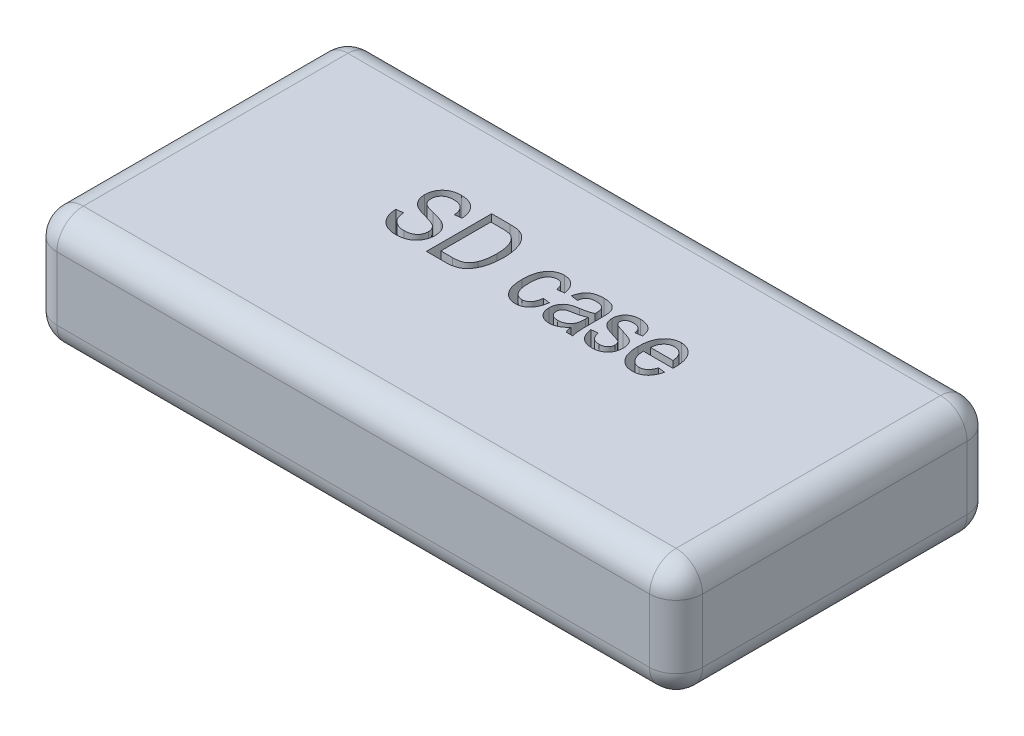
from build123d import *

# Parameters (mm, degrees)
SKETCH1_W           = 122
SKETCH1_H           = 60
BOSS_EXTRUDE1_DEPTH = 22
FILLET1_R           = 5
CUT_EXTRUDE1_DEPTH  = 23


with BuildPart() as part:
    # Sketch1 → Boss-Extrude1 (new body)
    with BuildSketch(Plane(origin=(0, 0, 0), x_dir=(1, 0, 0), z_dir=(0, 1, 0))):
        with Locations((56.214276145, -30)):
            Rectangle(SKETCH1_W, SKETCH1_H)
    extrude(amount=BOSS_EXTRUDE1_DEPTH)

    # Fillet1
    fillet1_edges = [part.edges().sort_by_distance(p)[0] for p in [
        (117.214276145, 22, 30),
        (56.214276145, 22, 0),
        (-4.785723855, 22, 30),
        (56.214276145, 0, 0),
        (117.214276145, 0, 30),
        (56.214276145, 0, 60),
        (-4.785723855, 0, 30),
        (-4.785723855, 11, 0),
        (117.214276145, 11, 0),
        (117.214276145, 11, 60),
        (-4.785723855, 11, 60),
        (56.214276145, 22, 60),
    ]]
    fillet(fillet1_edges, radius=FILLET1_R)

    # Sketch2 → Cut-Extrude1 (cut, through all)
    with BuildSketch(Plane(origin=(0, 22, 0), x_dir=(1, 0, 0), z_dir=(0, 1, 0))):
        with BuildLine():
            Line((30.277592906, -25.997425426), (31.55841677, -25.837322443))
            add(Edge.make_bspline(
                [(31.55841677, -25.837322443), (31.577066313, -26.00038168), (31.612435314, -26.309624773), (31.709305075, -26.742693066), (31.838868686, -27.118940399), (31.998936064, -27.445946572), (32.204060604, -27.72313712), (32.438365704, -27.972423696), (32.714343491, -28.189904924), (33.023274321, -28.379767363), (33.363302519, -28.533001799), (33.728113356, -28.638882457), (34.112557122, -28.706649404), (34.37577034, -28.714938862), (34.510315518, -28.719176136)],
                knots=[0, 0, 0, 0, 0.000492131, 0.00093333, 0.001328117, 0.001683882, 0.002020644, 0.00235862, 0.002707503, 0.00307133, 0.003444204, 0.003822551, 0.004208318, 0.004611706, 0.004611706, 0.004611706, 0.004611706], degree=3))
            add(Edge.make_bspline(
                [(34.510315518, -28.719176136), (34.606289806, -28.717225769), (34.792808014, -28.713435389), (35.064400108, -28.684926325), (35.320211863, -28.641980766), (35.557837712, -28.575170014), (35.781695147, -28.497041794), (35.985482284, -28.392881699), (36.176183321, -28.27516573), (36.348259767, -28.138113086), (36.499993433, -27.984070402), (36.637529507, -27.822402954), (36.749356762, -27.645416872), (36.84365281, -27.460090561), (36.912803688, -27.261861617), (36.966439022, -27.054677289), (36.996340563, -26.83466605), (37.00002984, -26.684619237), (37.00191819, -26.607818049)],
                knots=[0, 0, 0, 0, 0.000287859, 0.000559431, 0.000818537, 0.00106493, 0.001299175, 0.001528519, 0.001749936, 0.001970674, 0.00218648, 0.002397878, 0.002606053, 0.002813022, 0.003020339, 0.003234515, 0.003454216, 0.003684581, 0.003684581, 0.003684581, 0.003684581], degree=3))
            add(Edge.make_bspline(
                [(37.00191819, -26.607818049), (36.999164726, -26.519239483), (36.993801647, -26.346709956), (36.948152981, -26.095552712), (36.870319766, -25.862803318), (36.764360847, -25.646680063), (36.627512524, -25.448918545), (36.458509171, -25.270486461), (36.257688922, -25.112761562), (36.066067833, -24.993145513), (35.880958717, -24.906022024), (35.70607142, -24.830922657), (35.495451499, -24.751705286), (35.249440208, -24.666442309), (34.967959652, -24.577616667), (34.650854714, -24.482442924), (34.29923378, -24.379673344), (34.051792745, -24.311800444), (33.922437378, -24.276318359)],
                knots=[0, 0, 0, 0, 0.000265595, 0.000517315, 0.000762549, 0.000999727, 0.001237051, 0.001481262, 0.001734036, 0.002001334, 0.002156857, 0.002347374, 0.00257224, 0.002831733, 0.003128414, 0.003457639, 0.003824976, 0.00422737, 0.00422737, 0.00422737, 0.00422737], degree=3))
            add(Edge.make_bspline(
                [(33.922437378, -24.276318359), (33.806349655, -24.243564189), (33.582630724, -24.180441854), (33.261811788, -24.079421558), (32.966292112, -23.981362918), (32.697893266, -23.876745172), (32.453244467, -23.777388822), (32.237161985, -23.67076456), (32.046336696, -23.5663619), (31.826878867, -23.427858855), (31.587177658, -23.234149302), (31.3331276, -22.975307862), (31.11119846, -22.688692982), (30.92603839, -22.374329704), (30.77586493, -22.036078005), (30.676424658, -21.671467135), (30.60706887, -21.287860104), (30.600927725, -21.023717618), (30.597798872, -20.889139626)],
                knots=[0, 0, 0, 0, 0.000361835, 0.000697312, 0.001009001, 0.001295651, 0.001561399, 0.001800823, 0.002018045, 0.002213747, 0.002578648, 0.002939522, 0.003299788, 0.003663177, 0.004031738, 0.004406286, 0.004794519, 0.005197775, 0.005197775, 0.005197775, 0.005197775], degree=3))
            add(Edge.make_bspline(
                [(30.597798872, -20.889139626), (30.600559784, -20.76807724), (30.605987179, -20.530092984), (30.652319741, -20.181772345), (30.725760178, -19.849196535), (30.835347885, -19.535917672), (30.969423442, -19.237474036), (31.139216896, -18.95985585), (31.335554914, -18.696410222), (31.562869089, -18.453398878), (31.81323729, -18.230532002), (32.089523637, -18.03897683), (32.385895856, -17.876652768), (32.702415899, -17.739503585), (33.041993734, -17.638089679), (33.401401426, -17.566704951), (33.781118878, -17.519795733), (34.041536328, -17.514621238), (34.175099898, -17.51196733)],
                knots=[0, 0, 0, 0, 0.000363044, 0.000713671, 0.001052304, 0.00138299, 0.001707621, 0.002031963, 0.002357173, 0.002691725, 0.003028486, 0.003360899, 0.003697912, 0.004040842, 0.004393791, 0.004758803, 0.00513922, 0.005539759, 0.005539759, 0.005539759, 0.005539759], degree=3))
            add(Edge.make_bspline(
                [(34.175099898, -17.51196733), (34.35719142, -17.517050895), (34.712499826, -17.526970268), (35.227898377, -17.609929954), (35.707868725, -17.750473921), (36.150586229, -17.946043321), (36.552594363, -18.192936225), (36.906997964, -18.492649911), (37.21618248, -18.838481325), (37.473394422, -19.234151478), (37.68157221, -19.670613927), (37.834011705, -20.145937276), (37.933392967, -20.657569369), (37.952641474, -21.012094016), (37.962536088, -21.194335938)],
                knots=[0, 0, 0, 0, 0.000546045, 0.001065476, 0.001560997, 0.002042581, 0.002513263, 0.002971297, 0.003430211, 0.003899941, 0.004382206, 0.004876646, 0.00539376, 0.005940766, 0.005940766, 0.005940766, 0.005940766], degree=3))
            Line((37.962536088, -21.194335938), (36.681712225, -21.35443892))
            add(Edge.make_bspline(
                [(36.681712225, -21.35443892), (36.672316383, -21.255855325), (36.653993766, -21.063609704), (36.603368121, -20.78705463), (36.538662161, -20.529202847), (36.457537424, -20.29146418), (36.355599232, -20.074719086), (36.242103692, -19.876502208), (36.109906318, -19.698861729), (35.962414348, -19.540822493), (35.798008814, -19.402425539), (35.618890367, -19.281124751), (35.423536101, -19.178379604), (35.211598672, -19.096488274), (34.98583641, -19.030596046), (34.743501841, -18.986773115), (34.485955522, -18.958775941), (34.308595597, -18.954888205), (34.217627253, -18.952894176)],
                knots=[0, 0, 0, 0, 0.000296976, 0.000579126, 0.000842449, 0.001094032, 0.001331303, 0.001559991, 0.001778134, 0.001994056, 0.002207061, 0.002421456, 0.002641896, 0.002867665, 0.003102017, 0.003346356, 0.003605487, 0.003878346, 0.003878346, 0.003878346, 0.003878346], degree=3))
            add(Edge.make_bspline(
                [(34.217627253, -18.952894176), (34.12496947, -18.953687804), (33.945874581, -18.955221778), (33.685393724, -18.985480822), (33.441478957, -19.025443152), (33.213799227, -19.086298044), (33.004316567, -19.163098421), (32.810116594, -19.256871096), (32.633836752, -19.368477689), (32.474522462, -19.497163355), (32.335001513, -19.640255825), (32.21226177, -19.792436028), (32.107296669, -19.954292278), (32.025486803, -20.128266627), (31.960151715, -20.311772148), (31.912134491, -20.505178639), (31.884787204, -20.709076034), (31.880704887, -20.848199969), (31.878622736, -20.919158936)],
                knots=[0, 0, 0, 0, 0.00027778, 0.000536911, 0.00078573, 0.001018742, 0.001242731, 0.001454187, 0.001664471, 0.00186724, 0.002067134, 0.002262868, 0.002453007, 0.002644343, 0.002838198, 0.003036599, 0.00324109, 0.003453962, 0.003453962, 0.003453962, 0.003453962], degree=3))
            add(Edge.make_bspline(
                [(31.878622736, -20.919158936), (31.882866733, -21.046353442), (31.890936496, -21.28820789), (31.966380469, -21.628911676), (32.091957005, -21.927541614), (32.219319585, -22.090537568), (32.281381802, -22.16996349)],
                knots=[0, 0, 0, 0, 0.000381067, 0.00072458, 0.001041575, 0.00134285, 0.00134285, 0.00134285, 0.00134285], degree=3))
            add(Edge.make_bspline(
                [(32.281381802, -22.16996349), (32.319488239, -22.207962558), (32.402253437, -22.290494555), (32.561656377, -22.394476168), (32.751400623, -22.503868255), (32.981345141, -22.603083099), (33.243109591, -22.707112648), (33.543303106, -22.802487868), (33.878118321, -22.901169677), (34.115632096, -22.959771165), (34.240141735, -22.990491278)],
                knots=[0, 0, 0, 0, 0.000161058, 0.000349809, 0.000568253, 0.000817938, 0.001099922, 0.001413193, 0.001762317, 0.002146988, 0.002146988, 0.002146988, 0.002146988], degree=3))
            add(Edge.make_bspline(
                [(34.240141735, -22.990491278), (34.362826339, -23.020088817), (34.598564628, -23.076960446), (34.93663196, -23.165659234), (35.24720714, -23.247646214), (35.52982887, -23.326166707), (35.782534708, -23.407410278), (36.007556502, -23.482732314), (36.206173861, -23.549994878), (36.325928706, -23.601835484), (36.381519132, -23.625899991)],
                knots=[0, 0, 0, 0, 0.000378603, 0.000727486, 0.001048483, 0.001342281, 0.001607321, 0.001844645, 0.002054318, 0.002235973, 0.002235973, 0.002235973, 0.002235973], degree=3))
            add(Edge.make_bspline(
                [(36.381519132, -23.625899991), (36.531487022, -23.698436887), (36.82224802, -23.839072993), (37.209846207, -24.114742909), (37.541812503, -24.42798028), (37.811939846, -24.785731265), (38.025137733, -25.180114803), (38.174475639, -25.612690569), (38.266894499, -26.080235399), (38.277361555, -26.403911188), (38.282742054, -26.570293912)],
                knots=[0, 0, 0, 0, 0.000499026, 0.000967522, 0.001420486, 0.001863277, 0.002306507, 0.002759851, 0.00323133, 0.003730054, 0.003730054, 0.003730054, 0.003730054], degree=3))
            add(Edge.make_bspline(
                [(38.282742054, -26.570293912), (38.277301203, -26.73750355), (38.266550583, -27.067894408), (38.171132817, -27.551162626), (38.015229968, -28.011702412), (37.797164163, -28.442037744), (37.530298964, -28.83823705), (37.216256605, -29.189695089), (36.853635859, -29.487816068), (36.447526957, -29.733983491), (35.997900977, -29.929304965), (35.502824609, -30.060921728), (34.966047152, -30.146132063), (34.593218141, -30.15533804), (34.400244717, -30.160102983)],
                knots=[0, 0, 0, 0, 0.000501222, 0.000990368, 0.001471354, 0.001955775, 0.002433137, 0.002900784, 0.003364581, 0.003836087, 0.00432125, 0.004829834, 0.005369034, 0.005947561, 0.005947561, 0.005947561, 0.005947561], degree=3))
            add(Edge.make_bspline(
                [(34.400244717, -30.160102983), (34.248321693, -30.156917313), (33.951863766, -30.150700894), (33.519818787, -30.097172722), (33.111824833, -30.01007938), (32.726973174, -29.887341604), (32.364684178, -29.729131217), (32.025354683, -29.536166183), (31.710668936, -29.307105327), (31.423104761, -29.043553681), (31.163049356, -28.751139284), (30.933899332, -28.432303796), (30.740065153, -28.08628049), (30.581330632, -27.715890991), (30.452226089, -27.321799186), (30.357818979, -26.903116589), (30.297471446, -26.458534047), (30.284323324, -26.153546231), (30.277592906, -25.997425426)],
                knots=[0, 0, 0, 0, 0.000455629, 0.000889101, 0.001303712, 0.001705608, 0.002098807, 0.002487596, 0.002874384, 0.003263945, 0.003655548, 0.004046392, 0.004439535, 0.004842907, 0.005253484, 0.005681931, 0.006128768, 0.006597378, 0.006597378, 0.006597378, 0.006597378], degree=3))
        make_face()
        with BuildLine():
            Line((40.043874867, -30), (40.043874867, -17.672070313))
            Line((40.043874867, -17.672070313), (43.518609919, -17.672070313))
            add(Edge.make_bspline(
                [(43.518609919, -17.672070313), (43.622862719, -17.672038489), (43.82561532, -17.671976599), (44.119146833, -17.686123132), (44.393679166, -17.702592057), (44.648296468, -17.72694981), (44.88411411, -17.760671014), (45.101171219, -17.795397997), (45.297726462, -17.844163742), (45.420815562, -17.88170509), (45.47987146, -17.899716741)],
                knots=[0, 0, 0, 0, 0.000312711, 0.000608166, 0.000881403, 0.00113779, 0.00137518, 0.001596031, 0.001796862, 0.001982083, 0.001982083, 0.001982083, 0.001982083], degree=3))
            add(Edge.make_bspline(
                [(45.47987146, -17.899716741), (45.623609793, -17.954661081), (45.911188064, -18.064588597), (46.310238703, -18.308271532), (46.677773227, -18.612457819), (47.016577708, -18.974785403), (47.32034168, -19.394652229), (47.591562066, -19.864748041), (47.823540085, -20.386944988), (48.021275226, -20.959027591), (48.178697188, -21.583995364), (48.289500797, -22.263434758), (48.35744153, -22.997441755), (48.365211718, -23.505668294), (48.36922998, -23.76849171)],
                knots=[0, 0, 0, 0, 0.000460874, 0.000922073, 0.001394844, 0.001888625, 0.002405999, 0.002946213, 0.003513907, 0.004117542, 0.004760071, 0.005444822, 0.006180899, 0.006969228, 0.006969228, 0.006969228, 0.006969228], degree=3))
            add(Edge.make_bspline(
                [(48.36922998, -23.76849171), (48.367124244, -23.939467059), (48.362981925, -24.275802744), (48.335889237, -24.769986258), (48.28827708, -25.244924427), (48.221908332, -25.699331971), (48.133031109, -26.133893758), (48.02958977, -26.549578516), (47.903814833, -26.945102498), (47.762246504, -27.319444484), (47.604594016, -27.670050757), (47.43417798, -27.99533348), (47.255716131, -28.295711526), (47.06426524, -28.568411813), (46.861298004, -28.813820159), (46.649024901, -29.034873801), (46.425586223, -29.229742937), (46.18787596, -29.395157377), (45.937363457, -29.540433309), (45.668307208, -29.661559347), (45.382156962, -29.768140029), (45.076145963, -29.851429439), (44.753068914, -29.919700003), (44.411172446, -29.966679592), (44.05106639, -29.993879065), (43.804674587, -29.997929378), (43.678712902, -30)],
                knots=[0, 0, 0, 0, 0.000512927, 0.00100901, 0.001484197, 0.001944473, 0.002386019, 0.002814372, 0.003228945, 0.003630366, 0.004014418, 0.00438143, 0.004731513, 0.005061877, 0.005379935, 0.005686002, 0.005980406, 0.006267732, 0.006553507, 0.006847912, 0.007151834, 0.007468661, 0.007798361, 0.008141884, 0.008503165, 0.008881041, 0.008881041, 0.008881041, 0.008881041], degree=3))
            Line((43.678712902, -30), (40.043874867, -30))
        make_face()
        with BuildLine():
            Line((41.32469873, -28.559073153), (43.523613137, -28.559073153))
            add(Edge.make_bspline(
                [(43.523613137, -28.559073153), (43.631221496, -28.557570064), (43.839957854, -28.554654402), (44.142908822, -28.534020055), (44.426455812, -28.503519218), (44.688826066, -28.453908533), (44.933035283, -28.400367842), (45.153747394, -28.321923643), (45.358107249, -28.239399926), (45.542906226, -28.137613856), (45.711874637, -28.020659086), (45.870986214, -27.891022638), (46.016523975, -27.740847576), (46.153014589, -27.576464375), (46.282091573, -27.397479869), (46.400025987, -27.202116049), (46.504125383, -26.98830614), (46.566320258, -26.8391235), (46.598090731, -26.762917813)],
                knots=[0, 0, 0, 0, 0.000322795, 0.00062615, 0.000910697, 0.001177631, 0.001427016, 0.001659598, 0.001879356, 0.002087591, 0.0022909, 0.002495252, 0.002702222, 0.002917142, 0.003135829, 0.00336364, 0.003600818, 0.00384849, 0.00384849, 0.00384849, 0.00384849], degree=3))
            add(Edge.make_bspline(
                [(46.598090731, -26.762917813), (46.637624149, -26.655753615), (46.717800894, -26.438416554), (46.817712888, -26.100167062), (46.898452504, -25.746225063), (46.970699552, -25.377935019), (47.020484858, -24.99250059), (47.062257321, -24.59229575), (47.084010831, -24.176498146), (47.08692442, -23.894426915), (47.088406117, -23.750980447)],
                knots=[0, 0, 0, 0, 0.000342611, 0.000694841, 0.001057099, 0.001431447, 0.00182026, 0.002222514, 0.002638391, 0.003068733, 0.003068733, 0.003068733, 0.003068733], degree=3))
            add(Edge.make_bspline(
                [(47.088406117, -23.750980447), (47.087313086, -23.598338031), (47.085185167, -23.301172864), (47.058701543, -22.868146984), (47.02086035, -22.460473511), (46.961950171, -22.078405159), (46.891892644, -21.721012898), (46.800120101, -21.389107605), (46.697643554, -21.080987781), (46.573288095, -20.799518443), (46.437851896, -20.54230173), (46.2960204, -20.305349994), (46.142082208, -20.091921095), (45.981249918, -19.898074076), (45.806252863, -19.730650452), (45.627143514, -19.580804042), (45.434817059, -19.457023784), (45.299614066, -19.391046232), (45.232212158, -19.358154852)],
                knots=[0, 0, 0, 0, 0.000457856, 0.000891357, 0.001301079, 0.001685652, 0.002050664, 0.002392937, 0.002718079, 0.0030239, 0.003314829, 0.003589836, 0.003851562, 0.004103642, 0.004344239, 0.004577104, 0.004803316, 0.005028197, 0.005028197, 0.005028197, 0.005028197], degree=3))
            add(Edge.make_bspline(
                [(45.232212158, -19.358154852), (45.183319704, -19.33812475), (45.080441433, -19.295977914), (44.911779917, -19.247335559), (44.723795518, -19.205204309), (44.515988998, -19.169642317), (44.287688023, -19.14699046), (44.039323494, -19.125017874), (43.77047944, -19.117220127), (43.584483159, -19.114433722), (43.488590609, -19.112997159)],
                knots=[0, 0, 0, 0, 0.000158413, 0.000333329, 0.000525709, 0.000736276, 0.000965293, 0.001213759, 0.001484118, 0.001771847, 0.001771847, 0.001771847, 0.001771847], degree=3))
            Line((43.488590609, -19.112997159), (41.32469873, -19.112997159))
            Line((41.32469873, -19.112997159), (41.32469873, -28.559073153))
        make_face(mode=Mode.SUBTRACT)
        with BuildLine():
            Line((58.775923872, -26.637837358), (60.056747736, -26.797940341))
            add(Edge.make_bspline(
                [(60.056747736, -26.797940341), (60.03765799, -26.930834924), (60.000467988, -27.189735687), (59.916663643, -27.563925296), (59.81589303, -27.913983198), (59.691712873, -28.239739363), (59.550617378, -28.541423575), (59.389468759, -28.820240949), (59.206864969, -29.073510555), (59.0034143, -29.30080408), (58.787348891, -29.503802), (58.556084173, -29.6773526), (58.318138047, -29.828465892), (58.066554876, -29.948909344), (57.806024439, -30.046534137), (57.532141841, -30.107757763), (57.249887945, -30.154983102), (57.057530656, -30.158377576), (56.959755659, -30.160102983)],
                knots=[0, 0, 0, 0, 0.000402643, 0.000784415, 0.00114935, 0.001494554, 0.001829152, 0.002147516, 0.002459265, 0.002764031, 0.003061396, 0.003347084, 0.003630285, 0.003905519, 0.00418251, 0.004462835, 0.004746224, 0.00503918, 0.00503918, 0.00503918, 0.00503918], degree=3))
            add(Edge.make_bspline(
                [(56.959755659, -30.160102983), (56.841959719, -30.157030386), (56.610033216, -30.150980801), (56.270720627, -30.094470327), (55.947255802, -30.0017843), (55.640500833, -29.870127022), (55.34900123, -29.704482945), (55.07288723, -29.502130759), (54.816275475, -29.260341802), (54.574331109, -28.984644411), (54.357779898, -28.671319979), (54.165568643, -28.323501239), (54.006993533, -27.939442879), (53.877013798, -27.520576738), (53.774919985, -27.067234335), (53.703733364, -26.578841076), (53.661145124, -26.05572211), (53.65552969, -25.695647815), (53.652628418, -25.50961165)],
                knots=[0, 0, 0, 0, 0.000353161, 0.000695334, 0.001028649, 0.001360412, 0.00169428, 0.002032516, 0.002384746, 0.002749981, 0.003130965, 0.003525078, 0.003939961, 0.004375125, 0.004839388, 0.005332567, 0.005854636, 0.006412697, 0.006412697, 0.006412697, 0.006412697], degree=3))
            add(Edge.make_bspline(
                [(53.652628418, -25.50961165), (53.655639872, -25.321923696), (53.661470209, -24.958549722), (53.702477829, -24.43175654), (53.778133938, -23.942191206), (53.879885424, -23.487972164), (54.008434455, -23.068521377), (54.168438687, -22.685873265), (54.359204716, -22.339819434), (54.58040298, -22.031749204), (54.822874117, -21.759431963), (55.08150154, -21.521229459), (55.359184352, -21.322169849), (55.653753547, -21.158434129), (55.965013387, -21.029780101), (56.29368855, -20.940395665), (56.63753687, -20.883081956), (56.872801627, -20.877144965), (56.992276578, -20.874129972)],
                knots=[0, 0, 0, 0, 0.000563062, 0.001090119, 0.001583672, 0.002047934, 0.002485487, 0.002898063, 0.003289986, 0.003668325, 0.004033337, 0.004382175, 0.004720965, 0.005055788, 0.0053912, 0.005728648, 0.00607576, 0.006433918, 0.006433918, 0.006433918, 0.006433918], degree=3))
            add(Edge.make_bspline(
                [(56.992276578, -20.874129972), (57.084977559, -20.875502017), (57.26774214, -20.878207073), (57.535158456, -20.916006462), (57.792433886, -20.968438337), (58.035811293, -21.051204028), (58.270972943, -21.150025143), (58.492608626, -21.276444865), (58.705634693, -21.422249921), (58.904302755, -21.59240134), (59.091719752, -21.783723205), (59.260892692, -21.998485838), (59.412649151, -22.236418945), (59.544028144, -22.49686602), (59.659532781, -22.77981064), (59.759325909, -23.083783134), (59.839885346, -23.411721345), (59.877348007, -23.638943285), (59.896644753, -23.755983665)],
                knots=[0, 0, 0, 0, 0.000277859, 0.000547812, 0.000808844, 0.001064364, 0.00131762, 0.001572993, 0.001828353, 0.00209101, 0.002356369, 0.002630635, 0.002909607, 0.00320161, 0.003504501, 0.003825683, 0.004160599, 0.004516365, 0.004516365, 0.004516365, 0.004516365], degree=3))
            Line((59.896644753, -23.755983665), (58.615820889, -23.916086648))
            add(Edge.make_bspline(
                [(58.615820889, -23.916086648), (58.584856715, -23.776779195), (58.526275362, -23.513222389), (58.393357998, -23.150926434), (58.22917637, -22.842647127), (58.029678368, -22.592074121), (57.805416993, -22.394009897), (57.553730018, -22.256890625), (57.281461984, -22.169804625), (57.091328899, -22.159955354), (56.994778187, -22.154953835)],
                knots=[0, 0, 0, 0, 0.000427746, 0.000809256, 0.001154051, 0.001470898, 0.001765302, 0.002045214, 0.002325327, 0.002614326, 0.002614326, 0.002614326, 0.002614326], degree=3))
            add(Edge.make_bspline(
                [(56.994778187, -22.154953835), (56.922054074, -22.157236453), (56.778941728, -22.161728372), (56.568951951, -22.201048283), (56.368424007, -22.262566293), (56.178130555, -22.352263924), (55.998041071, -22.465354314), (55.825505771, -22.602344946), (55.663224477, -22.764941996), (55.513446869, -22.954361497), (55.373013713, -23.167273967), (55.257794482, -23.413661773), (55.153000935, -23.685982386), (55.076957127, -23.99078969), (55.009846238, -24.321766509), (54.967231982, -24.683191267), (54.939112472, -25.073882291), (54.935383683, -25.344449716), (54.933452281, -25.484595559)],
                knots=[0, 0, 0, 0, 0.000217999, 0.000428996, 0.000638669, 0.000845714, 0.001058115, 0.001275338, 0.001505296, 0.001745567, 0.001998836, 0.002268477, 0.002559804, 0.002872905, 0.003209462, 0.003572497, 0.003963717, 0.004384107, 0.004384107, 0.004384107, 0.004384107], degree=3))
            add(Edge.make_bspline(
                [(54.933452281, -25.484595559), (54.935720633, -25.628882186), (54.940090413, -25.906837747), (54.963608492, -26.308667862), (55.008711207, -26.679476428), (55.070454556, -27.020553432), (55.149300419, -27.331257661), (55.246932217, -27.610996819), (55.360713391, -27.86017765), (55.494765884, -28.077680342), (55.643276371, -28.265906835), (55.801166153, -28.429019018), (55.967439162, -28.569638931), (56.146210053, -28.682434329), (56.335251486, -28.771102889), (56.533857632, -28.833263721), (56.742230124, -28.872644101), (56.88452705, -28.877034974), (56.95725405, -28.879279119)],
                knots=[0, 0, 0, 0, 0.000432894, 0.000833932, 0.001206899, 0.001552818, 0.00187318, 0.0021675, 0.002440588, 0.0026933, 0.002932017, 0.003158464, 0.003373385, 0.003583669, 0.003790714, 0.003998, 0.004206536, 0.004424535, 0.004424535, 0.004424535, 0.004424535], degree=3))
            add(Edge.make_bspline(
                [(56.95725405, -28.879279119), (57.014100331, -28.878342602), (57.126827649, -28.87648547), (57.292341756, -28.846195473), (57.453184204, -28.805443696), (57.605899107, -28.743836426), (57.753542009, -28.669587979), (57.89046886, -28.572105596), (58.024271522, -28.461778027), (58.151897813, -28.334569443), (58.270216613, -28.187960139), (58.378313358, -28.022417969), (58.472018626, -27.836052702), (58.557606116, -27.633337325), (58.630240579, -27.411605255), (58.689135487, -27.170460795), (58.739330697, -26.910788282), (58.76349558, -26.730540817), (58.775923872, -26.637837358)],
                knots=[0, 0, 0, 0, 0.000170275, 0.000337659, 0.000503313, 0.000667298, 0.000830651, 0.000997885, 0.001170206, 0.001350634, 0.001537385, 0.001734442, 0.001942542, 0.0021623, 0.002394087, 0.002641632, 0.002906567, 0.003187115, 0.003187115, 0.003187115, 0.003187115], degree=3))
        make_face()
        with BuildLine():
            add(Edge.make_bspline(
                [(66.140661088, -28.7642051), (66.035641383, -28.874359323), (65.83146899, -29.088513907), (65.504425708, -29.372666931), (65.170882873, -29.614656501), (64.830401481, -29.813947941), (64.482689504, -29.967575667), (64.129955972, -30.07956079), (63.769176377, -30.146563153), (63.525918618, -30.155580093), (63.403900723, -30.160102983)],
                knots=[0, 0, 0, 0, 0.000456391, 0.000887286, 0.001297618, 0.001691071, 0.002068516, 0.002435631, 0.002799226, 0.003165154, 0.003165154, 0.003165154, 0.003165154], degree=3))
            add(Edge.make_bspline(
                [(63.403900723, -30.160102983), (63.309555903, -30.158557385), (63.12527512, -30.155538418), (62.856081566, -30.120949478), (62.600789679, -30.070824013), (62.361090086, -29.993686761), (62.134517381, -29.899895416), (61.923980133, -29.780956762), (61.726719039, -29.643116835), (61.547613239, -29.482381024), (61.384421501, -29.305795493), (61.243916392, -29.111078702), (61.122835127, -28.902951519), (61.024849951, -28.678797118), (60.950887712, -28.440137178), (60.894817573, -28.187667338), (60.862309626, -27.92035299), (60.858966691, -27.736965092), (60.857262651, -27.64348422)],
                knots=[0, 0, 0, 0, 0.000282859, 0.000552499, 0.000813015, 0.001062236, 0.001306627, 0.001547419, 0.001786175, 0.002027162, 0.002267967, 0.002506146, 0.002746001, 0.002989082, 0.003238303, 0.003494446, 0.003764087, 0.004044446, 0.004044446, 0.004044446, 0.004044446], degree=3))
            add(Edge.make_bspline(
                [(60.857262651, -27.64348422), (60.860577211, -27.518928832), (60.867028972, -27.276482872), (60.932710463, -26.924624208), (61.033737328, -26.593961897), (61.18053041, -26.28747455), (61.362100999, -26.008807542), (61.575132274, -25.759107409), (61.819497332, -25.543160091), (62.048447734, -25.389293994), (62.251940694, -25.282580736), (62.424585916, -25.208479763), (62.615103337, -25.138802296), (62.82338727, -25.072898878), (63.051091162, -25.016946544), (63.297134682, -24.964070814), (63.561683965, -24.916846692), (63.744870994, -24.890347208), (63.839180708, -24.876704545)],
                knots=[0, 0, 0, 0, 0.000373277, 0.00072658, 0.001069966, 0.001407896, 0.001742336, 0.002065228, 0.002389522, 0.0027177, 0.002890021, 0.003078241, 0.003280856, 0.003498438, 0.003733243, 0.003983966, 0.004253363, 0.004539226, 0.004539226, 0.004539226, 0.004539226], degree=3))
            add(Edge.make_bspline(
                [(63.839180708, -24.876704545), (63.966077492, -24.854977706), (64.211299434, -24.812991631), (64.563778077, -24.739458697), (64.89118175, -24.665244747), (65.1909999, -24.584968593), (65.467082864, -24.505645631), (65.715498922, -24.420581958), (65.939876931, -24.335231636), (66.076053963, -24.26812862), (66.140661088, -24.236292614)],
                knots=[0, 0, 0, 0, 0.000386197, 0.000746307, 0.001080063, 0.001393164, 0.001677348, 0.001941573, 0.002180813, 0.002396779, 0.002396779, 0.002396779, 0.002396779], degree=3))
            Line((66.140661088, -24.236292614), (66.140661088, -23.871057684))
            add(Edge.make_bspline(
                [(66.140661088, -23.871057684), (66.14012615, -23.801787735), (66.139099457, -23.668839893), (66.119543695, -23.477833169), (66.096516013, -23.301864943), (66.059917498, -23.141422309), (66.008412585, -22.998360313), (65.951995461, -22.868752562), (65.882716758, -22.755166463), (65.825583376, -22.691218632), (65.79794064, -22.660278875)],
                knots=[0, 0, 0, 0, 0.000207694, 0.000398621, 0.000575511, 0.000739953, 0.000891067, 0.001031024, 0.001163609, 0.001287886, 0.001287886, 0.001287886, 0.001287886], degree=3))
            add(Edge.make_bspline(
                [(65.79794064, -22.660278875), (65.756438727, -22.619885605), (65.672433171, -22.538124093), (65.525018514, -22.435898279), (65.361882419, -22.348646412), (65.183576901, -22.275688401), (64.988958607, -22.220219199), (64.777400018, -22.185056782), (64.550323675, -22.157999929), (64.392960452, -22.155988746), (64.31198483, -22.154953835)],
                knots=[0, 0, 0, 0, 0.000173497, 0.000351182, 0.000535861, 0.00072772, 0.000928052, 0.001141511, 0.001370528, 0.0016133, 0.0016133, 0.0016133, 0.0016133], degree=3))
            add(Edge.make_bspline(
                [(64.31198483, -22.154953835), (64.169887487, -22.15759843), (63.903970642, -22.162547449), (63.532995652, -22.22936158), (63.216050601, -22.329814018), (62.992360055, -22.457363536), (62.844026586, -22.58553927), (62.741853553, -22.697659615), (62.649278304, -22.829534505), (62.56421511, -22.979081475), (62.483778027, -23.145601615), (62.415242264, -23.333260574), (62.348818327, -23.537016048), (62.315420084, -23.681462082), (62.298189497, -23.755983665)],
                knots=[0, 0, 0, 0, 0.000425744, 0.000796725, 0.001126606, 0.001419219, 0.001561129, 0.001713419, 0.001873072, 0.002043421, 0.002229164, 0.002427092, 0.002642288, 0.002871633, 0.002871633, 0.002871633, 0.002871633], degree=3))
            Line((62.298189497, -23.755983665), (61.017365634, -23.595880682))
            add(Edge.make_bspline(
                [(61.017365634, -23.595880682), (61.041937718, -23.481345085), (61.089818303, -23.258163719), (61.181063814, -22.936922763), (61.294644595, -22.640472353), (61.423430891, -22.368037984), (61.570010801, -22.120238435), (61.731921621, -21.895272785), (61.916527859, -21.698038583), (62.115167148, -21.519984419), (62.336147073, -21.365838611), (62.578693352, -21.233530896), (62.844526437, -21.124285858), (63.129887756, -21.030211314), (63.439572791, -20.962673259), (63.770039191, -20.908840792), (64.123840555, -20.879715674), (64.366972495, -20.876027893), (64.492100686, -20.874129972)],
                knots=[0, 0, 0, 0, 0.000351385, 0.0006847, 0.001000627, 0.001302742, 0.001587618, 0.001863318, 0.002132401, 0.002396448, 0.002662255, 0.00293877, 0.003223569, 0.003523397, 0.003838967, 0.004173332, 0.004527334, 0.004902709, 0.004902709, 0.004902709, 0.004902709], degree=3))
            add(Edge.make_bspline(
                [(64.492100686, -20.874129972), (64.589702332, -20.875645493), (64.779278337, -20.878589157), (65.055614682, -20.899196217), (65.315652427, -20.930395846), (65.559958786, -20.977582448), (65.787295913, -21.041473581), (66.000990145, -21.112034186), (66.197381662, -21.199608383), (66.429365474, -21.335285087), (66.68449808, -21.523763006), (66.94076266, -21.77849417), (67.128340456, -22.066309793), (67.231490809, -22.328109992), (67.286378595, -22.553444263), (67.324325946, -22.740232973), (67.353276341, -22.946697063), (67.378168594, -23.171114318), (67.397727057, -23.413891562), (67.41333965, -23.674079735), (67.419973028, -23.952741517), (67.420969479, -24.144565287), (67.421484952, -24.243797441)],
                knots=[0, 0, 0, 0, 0.000292784, 0.000568688, 0.00083088, 0.001078148, 0.001314228, 0.0015389, 0.00175277, 0.001957871, 0.002344125, 0.002701461, 0.003035901, 0.003367116, 0.003540035, 0.003731371, 0.003938688, 0.004165219, 0.004408699, 0.004669299, 0.004947079, 0.005244781, 0.005244781, 0.005244781, 0.005244781], degree=3))
            Line((67.421484952, -24.243797441), (67.421484952, -26.260094383))
            add(Edge.make_bspline(
                [(67.421484952, -26.260094383), (67.420943263, -26.428539473), (67.419913489, -26.748761085), (67.426812574, -27.204863771), (67.430101038, -27.611837499), (67.439218805, -27.97034751), (67.444058112, -28.279877037), (67.458241418, -28.539931044), (67.469142651, -28.751102041), (67.497247549, -29.058296619), (67.572038784, -29.475256187), (67.685163507, -29.825157466), (67.741690918, -30)],
                knots=[0, 0, 0, 0, 0.000505325, 0.000960645, 0.001368438, 0.001726247, 0.002036537, 0.002297005, 0.002507512, 0.002670808, 0.003222355, 0.00377322, 0.00377322, 0.00377322, 0.00377322], degree=3))
            Line((67.741690918, -30), (66.460867054, -30))
            add(Edge.make_bspline(
                [(66.460867054, -30), (66.421439299, -29.909819169), (66.340763033, -29.725293), (66.252942521, -29.426002886), (66.181700077, -29.104336163), (66.15458389, -28.879597258), (66.140661088, -28.7642051)],
                knots=[0, 0, 0, 0, 0.000294999, 0.000603621, 0.000933843, 0.001282322, 0.001282322, 0.001282322, 0.001282322], degree=3))
        make_face()
        with BuildLine():
            add(Edge.make_bspline(
                [(66.140661088, -25.517116477), (66.076734445, -25.548573575), (65.943732107, -25.61402152), (65.730221099, -25.704024394), (65.494704989, -25.789033259), (65.235820249, -25.867345212), (64.95639105, -25.948781039), (64.654056, -26.022718223), (64.330232359, -26.092751055), (64.106948053, -26.135485926), (63.991778864, -26.157528409)],
                knots=[0, 0, 0, 0, 0.000213708, 0.00044463, 0.000694691, 0.000964505, 0.001255897, 0.001567757, 0.001897979, 0.002249746, 0.002249746, 0.002249746, 0.002249746], degree=3))
            add(Edge.make_bspline(
                [(63.991778864, -26.157528409), (63.864049749, -26.178315241), (63.628654367, -26.216623847), (63.306239, -26.28198367), (63.046837878, -26.355325344), (62.8411165, -26.433780754), (62.677579254, -26.525981842), (62.538589723, -26.631944747), (62.417003075, -26.755023799), (62.317489639, -26.896139634), (62.236928436, -27.048974166), (62.177897684, -27.213750174), (62.146329861, -27.390457323), (62.140871493, -27.511619548), (62.138086514, -27.573439165)],
                knots=[0, 0, 0, 0, 0.000388233, 0.000715485, 0.000986261, 0.001196232, 0.001374339, 0.001547457, 0.00171905, 0.001891207, 0.002063528, 0.002236012, 0.002414119, 0.00259966, 0.00259966, 0.00259966, 0.00259966], degree=3))
            add(Edge.make_bspline(
                [(62.138086514, -27.573439165), (62.141824443, -27.668401692), (62.149021989, -27.851256242), (62.235171019, -28.109051463), (62.36534575, -28.339414313), (62.552800804, -28.534141623), (62.78548133, -28.690525057), (63.062036352, -28.799551647), (63.37637596, -28.868351763), (63.5994684, -28.875517033), (63.716601862, -28.879279119)],
                knots=[0, 0, 0, 0, 0.000283787, 0.000546444, 0.000806467, 0.001071897, 0.001349429, 0.001641164, 0.001958632, 0.00230958, 0.00230958, 0.00230958, 0.00230958], degree=3))
            add(Edge.make_bspline(
                [(63.716601862, -28.879279119), (63.83116093, -28.875818733), (64.057049141, -28.868995525), (64.38722564, -28.803201253), (64.702761568, -28.701866496), (64.997059597, -28.555533966), (65.266373211, -28.377708309), (65.50188466, -28.167509971), (65.701866286, -27.930713586), (65.837199345, -27.708519623), (65.926661776, -27.513742508), (65.98422798, -27.350400663), (66.029713214, -27.171497794), (66.074963733, -26.978772794), (66.102012648, -26.76834748), (66.12573393, -26.543245967), (66.137254868, -26.30190269), (66.139499795, -26.135855102), (66.140661088, -26.049959217)],
                knots=[0, 0, 0, 0, 0.000343304, 0.000676929, 0.001006022, 0.001334943, 0.001659651, 0.001971481, 0.002278649, 0.002586266, 0.002748582, 0.002921066, 0.00310493, 0.003302192, 0.003514461, 0.003740729, 0.003981209, 0.004238923, 0.004238923, 0.004238923, 0.004238923], degree=3))
            Line((66.140661088, -26.049959217), (66.140661088, -25.517116477))
        make_face(mode=Mode.SUBTRACT)
        with BuildLine():
            Line((68.38210285, -27.27824929), (69.662926713, -27.118146307))
            add(Edge.make_bspline(
                [(69.662926713, -27.118146307), (69.684600607, -27.258318877), (69.725684145, -27.524020326), (69.849132338, -27.890824434), (70.018443733, -28.201989053), (70.239129561, -28.454617616), (70.504813656, -28.647826098), (70.81092839, -28.78359852), (71.155563568, -28.864796006), (71.397748134, -28.874313), (71.52412389, -28.879279119)],
                knots=[0, 0, 0, 0, 0.000424906, 0.000805422, 0.001154824, 0.001480994, 0.001803226, 0.002132413, 0.002479489, 0.002858232, 0.002858232, 0.002858232, 0.002858232], degree=3))
            add(Edge.make_bspline(
                [(71.52412389, -28.879279119), (71.649615196, -28.874910543), (71.88710696, -28.86664303), (72.221839339, -28.793507518), (72.513290209, -28.672448209), (72.753997572, -28.496015161), (72.945248037, -28.284894169), (73.088080929, -28.045269587), (73.169967038, -27.774567634), (73.180017272, -27.585657871), (73.185192338, -27.488384455)],
                knots=[0, 0, 0, 0, 0.000376074, 0.000711719, 0.00102213, 0.001315854, 0.001599232, 0.001871678, 0.002146274, 0.002437763, 0.002437763, 0.002437763, 0.002437763], degree=3))
            add(Edge.make_bspline(
                [(73.185192338, -27.488384455), (73.182444286, -27.405459604), (73.177211467, -27.247554754), (73.121191355, -27.025607008), (73.028694377, -26.831302462), (72.937571345, -26.726964538), (72.892504072, -26.675361495)],
                knots=[0, 0, 0, 0, 0.000248278, 0.000472768, 0.000681978, 0.000886698, 0.000886698, 0.000886698, 0.000886698], degree=3))
            add(Edge.make_bspline(
                [(72.892504072, -26.675361495), (72.872057405, -26.658128863), (72.824666209, -26.618187144), (72.734160598, -26.566086272), (72.620872344, -26.508033264), (72.482108497, -26.448000585), (72.317485374, -26.387563469), (72.12905043, -26.318300133), (71.914989551, -26.249762319), (71.763511646, -26.20399689), (71.684226873, -26.180042891)],
                knots=[0, 0, 0, 0, 8.0091e-05, 0.000185634, 0.000312058, 0.000462175, 0.000638729, 0.000838137, 0.001064391, 0.00131287, 0.00131287, 0.00131287, 0.00131287], degree=3))
            add(Edge.make_bspline(
                [(71.684226873, -26.180042891), (71.567382007, -26.144516358), (71.343304972, -26.076386021), (71.022470581, -25.973101443), (70.729872832, -25.876793385), (70.466178642, -25.781883318), (70.232044872, -25.688258837), (70.02310745, -25.60454559), (69.843050121, -25.523006097), (69.644741264, -25.417484664), (69.427938685, -25.275678119), (69.199010167, -25.080687735), (69.002301512, -24.857654578), (68.83567842, -24.612103668), (68.706310627, -24.342712651), (68.609009791, -24.055087833), (68.554713033, -23.748007939), (68.546421821, -23.537709082), (68.542205833, -23.430774481)],
                knots=[0, 0, 0, 0, 0.000366373, 0.000702604, 0.001011125, 0.001290466, 0.001543178, 0.001767557, 0.00196569, 0.0021358, 0.002441088, 0.002740916, 0.003035087, 0.003330658, 0.003628265, 0.003928875, 0.004238994, 0.004559825, 0.004559825, 0.004559825, 0.004559825], degree=3))
            add(Edge.make_bspline(
                [(68.542205833, -23.430774481), (68.544626968, -23.338090348), (68.549356294, -23.157045741), (68.585904724, -22.891702384), (68.641889139, -22.638929293), (68.724493855, -22.399396737), (68.834187622, -22.176265829), (68.961554521, -21.963481218), (69.115694616, -21.764986819), (69.292991477, -21.581057913), (69.489198493, -21.412735563), (69.707833497, -21.269457999), (69.943114507, -21.146556925), (70.197299473, -21.046558183), (70.468760891, -20.968785151), (70.757845727, -20.915423395), (71.064518861, -20.877957512), (71.275509295, -20.875430011), (71.38403378, -20.874129972)],
                knots=[0, 0, 0, 0, 0.00027796, 0.000542954, 0.000802085, 0.001053667, 0.001300935, 0.001546768, 0.001796453, 0.002052999, 0.00231213, 0.002570233, 0.002835415, 0.003107171, 0.003388254, 0.003681156, 0.003988356, 0.004313719, 0.004313719, 0.004313719, 0.004313719], degree=3))
            add(Edge.make_bspline(
                [(71.38403378, -20.874129972), (71.520122221, -20.878252272), (71.785108767, -20.886279067), (72.169885486, -20.940418395), (72.529011436, -21.036443023), (72.86017448, -21.168494922), (73.16172042, -21.330101603), (73.426656588, -21.521273963), (73.654401871, -21.73804645), (73.84832536, -21.984298293), (74.005809542, -22.273823397), (74.133872968, -22.612446751), (74.239363555, -23.00456958), (74.282918698, -23.286784852), (74.305913219, -23.435777699)],
                knots=[0, 0, 0, 0, 0.000408253, 0.000794936, 0.001162664, 0.001520822, 0.001862226, 0.002186481, 0.002497888, 0.002802644, 0.003122889, 0.00348246, 0.003886607, 0.004338596, 0.004338596, 0.004338596, 0.004338596], degree=3))
            Line((74.305913219, -23.435777699), (73.025089355, -23.595880682))
            add(Edge.make_bspline(
                [(73.025089355, -23.595880682), (73.00753733, -23.482631659), (72.97417788, -23.267390116), (72.874879011, -22.968462047), (72.730158143, -22.717367987), (72.549593055, -22.506611589), (72.323615349, -22.347418392), (72.059703871, -22.233835497), (71.756798813, -22.16606648), (71.542001815, -22.158783294), (71.429062744, -22.154953835)],
                knots=[0, 0, 0, 0, 0.000343459, 0.00065278, 0.000938555, 0.00120801, 0.001478751, 0.001759934, 0.002065192, 0.002403659, 0.002403659, 0.002403659, 0.002403659], degree=3))
            add(Edge.make_bspline(
                [(71.429062744, -22.154953835), (71.302041646, -22.158378404), (71.064027568, -22.164795412), (70.732162291, -22.222114807), (70.448664086, -22.313711738), (70.218879105, -22.450359788), (70.042673475, -22.617962883), (69.915742142, -22.80834348), (69.836115445, -23.022025815), (69.827460017, -23.173252529), (69.823029696, -23.250658625)],
                knots=[0, 0, 0, 0, 0.000380771, 0.000713494, 0.001006994, 0.001269556, 0.001508417, 0.001730441, 0.001951221, 0.002182725, 0.002182725, 0.002182725, 0.002182725], degree=3))
            add(Edge.make_bspline(
                [(69.823029696, -23.250658625), (69.827271244, -23.325669895), (69.83557609, -23.472540082), (69.917935653, -23.67716119), (70.047209154, -23.858756441), (70.166205597, -23.949036005), (70.228290372, -23.996138139)],
                knots=[0, 0, 0, 0, 0.000224044, 0.000438673, 0.000651839, 0.000884381, 0.000884381, 0.000884381, 0.000884381], degree=3))
            add(Edge.make_bspline(
                [(70.228290372, -23.996138139), (70.25312203, -24.010659067), (70.311453583, -24.044769887), (70.417027022, -24.093609131), (70.552357535, -24.148383802), (70.717582238, -24.206814397), (70.91097248, -24.276222216), (71.135561313, -24.346317894), (71.389006786, -24.428380101), (71.569006463, -24.481088737), (71.664214, -24.508968006)],
                knots=[0, 0, 0, 0, 8.626e-05, 0.000202632, 0.0003485, 0.000524183, 0.000728306, 0.00096485, 0.001229891, 0.001527488, 0.001527488, 0.001527488, 0.001527488], degree=3))
            add(Edge.make_bspline(
                [(71.664214, -24.508968006), (71.787771644, -24.546023961), (72.022976375, -24.616563795), (72.356466006, -24.724519708), (72.654353997, -24.826732882), (72.916599041, -24.923453185), (73.143027882, -25.015542201), (73.332523612, -25.103794634), (73.489950482, -25.180681685), (73.646506063, -25.285427925), (73.809676154, -25.423372184), (73.979528947, -25.610482332), (74.125066065, -25.825563), (74.247863704, -26.066675356), (74.344169807, -26.333288561), (74.418840335, -26.622620858), (74.456470698, -26.937879661), (74.462761194, -27.155589327), (74.466016202, -27.268242853)],
                knots=[0, 0, 0, 0, 0.000386974, 0.000736645, 0.00105151, 0.001331712, 0.001575141, 0.001784456, 0.001958995, 0.002099843, 0.002348398, 0.00259812, 0.002855543, 0.003125172, 0.003407721, 0.003704412, 0.004019665, 0.004357715, 0.004357715, 0.004357715, 0.004357715], degree=3))
            add(Edge.make_bspline(
                [(74.466016202, -27.268242853), (74.463635506, -27.37340607), (74.458971634, -27.579424786), (74.421759077, -27.881335398), (74.355168173, -28.16698907), (74.269846873, -28.439206372), (74.151918804, -28.693702891), (74.012961214, -28.934573614), (73.845717445, -29.158509688), (73.656106836, -29.36622641), (73.443872092, -29.553152413), (73.21320655, -29.717353534), (72.961988057, -29.852671651), (72.693445021, -29.96611826), (72.404803082, -30.053007119), (72.098322966, -30.115080191), (71.773591022, -30.153456705), (71.550916715, -30.157847958), (71.436567571, -30.160102983)],
                knots=[0, 0, 0, 0, 0.000315451, 0.00061798, 0.000910487, 0.001194494, 0.001472127, 0.001750155, 0.002027337, 0.002308865, 0.002592442, 0.002874237, 0.003156343, 0.003446724, 0.003747438, 0.004058976, 0.004383858, 0.004726806, 0.004726806, 0.004726806, 0.004726806], degree=3))
            add(Edge.make_bspline(
                [(71.436567571, -30.160102983), (71.329767682, -30.157340909), (71.121504892, -30.151954787), (70.816545793, -30.120448675), (70.529938015, -30.062133726), (70.258492695, -29.985615321), (70.006896042, -29.882451615), (69.770246615, -29.759422519), (69.553512449, -29.610772765), (69.350305104, -29.442740843), (69.168817669, -29.248575836), (69.001178158, -29.034500916), (68.855131302, -28.7959646), (68.723440263, -28.536232329), (68.612174955, -28.253516418), (68.517423318, -27.948104591), (68.436122442, -27.62187421), (68.40037734, -27.39449545), (68.38210285, -27.27824929)],
                knots=[0, 0, 0, 0, 0.00032045, 0.000624887, 0.000918269, 0.001196949, 0.001469636, 0.001732602, 0.001995569, 0.002256613, 0.002522043, 0.002791254, 0.003071009, 0.00335965, 0.003663922, 0.003981193, 0.004318539, 0.004671408, 0.004671408, 0.004671408, 0.004671408], degree=3))
        make_face()
        with BuildLine():
            Line((81.030238503, -27.118146307), (82.311062367, -27.27824929))
            add(Edge.make_bspline(
                [(82.311062367, -27.27824929), (82.283469689, -27.393761718), (82.229399323, -27.620118843), (82.123190101, -27.944685852), (82.004313636, -28.249047592), (81.866253319, -28.529739307), (81.712856557, -28.788780019), (81.545797233, -29.027941708), (81.359936586, -29.244362469), (81.156785982, -29.436524989), (80.94099675, -29.607651335), (80.711825555, -29.75651899), (80.469681717, -29.881571052), (80.214216008, -29.981425831), (79.948476157, -30.062131233), (79.669007482, -30.120329361), (79.376560561, -30.151715501), (79.177448278, -30.157280875), (79.076481789, -30.160102983)],
                knots=[0, 0, 0, 0, 0.000356152, 0.000697913, 0.001023555, 0.001335695, 0.001635157, 0.001925969, 0.002209788, 0.002489365, 0.002763631, 0.003034937, 0.003307934, 0.003579689, 0.00385668, 0.004140257, 0.004434746, 0.004737699, 0.004737699, 0.004737699, 0.004737699], degree=3))
            add(Edge.make_bspline(
                [(79.076481789, -30.160102983), (78.949518342, -30.157081363), (78.700182015, -30.151147373), (78.335312595, -30.094226094), (77.988849887, -30.003321957), (77.662622726, -29.87011949), (77.354010496, -29.705431748), (77.062700038, -29.503170295), (76.793196911, -29.261432091), (76.542048872, -28.985855109), (76.316414071, -28.675028486), (76.121631941, -28.329237967), (75.952739508, -27.953109021), (75.818978411, -27.542602856), (75.714157909, -27.100768309), (75.640347472, -26.626526273), (75.594685782, -26.120069006), (75.589438066, -25.771547655), (75.586737083, -25.592164751)],
                knots=[0, 0, 0, 0, 0.000380648, 0.000747532, 0.001104947, 0.001452887, 0.001802083, 0.002152532, 0.002514012, 0.002885903, 0.003269197, 0.003663571, 0.004074544, 0.0045041, 0.004956746, 0.005435469, 0.005942797, 0.006480852, 0.006480852, 0.006480852, 0.006480852], degree=3))
            add(Edge.make_bspline(
                [(75.586737083, -25.592164751), (75.589221494, -25.406100708), (75.594054193, -25.044167355), (75.64276409, -24.518562791), (75.719197125, -24.026941972), (75.825251823, -23.56938795), (75.966194933, -23.146909981), (76.13550545, -22.757515626), (76.336536637, -22.401242755), (76.568851507, -22.081133378), (76.827165151, -21.799247713), (77.1005765, -21.552166835), (77.390481062, -21.341151531), (77.698915203, -21.171975628), (78.023008053, -21.036630557), (78.364066019, -20.941925204), (78.721945757, -20.886500815), (78.965384782, -20.878295953), (79.088989835, -20.874129972)],
                knots=[0, 0, 0, 0, 0.000558061, 0.001085544, 0.001581955, 0.002049782, 0.002492786, 0.002916209, 0.003321755, 0.003717555, 0.004100048, 0.004466728, 0.004821516, 0.005173105, 0.005519675, 0.005872925, 0.006232392, 0.00660317, 0.00660317, 0.00660317, 0.00660317], degree=3))
            add(Edge.make_bspline(
                [(79.088989835, -20.874129972), (79.207615673, -20.877202796), (79.441192314, -20.883253249), (79.783814944, -20.939900113), (80.110813953, -21.033023117), (80.423599539, -21.161113552), (80.720558498, -21.326839927), (80.999352167, -21.532966849), (81.266076298, -21.771399761), (81.51581276, -22.046589171), (81.743678428, -22.356647633), (81.942425099, -22.701144706), (82.106089284, -23.079890525), (82.245218205, -23.488421937), (82.347596751, -23.931349295), (82.426282159, -24.405700162), (82.470323385, -24.913393088), (82.475838377, -25.262705614), (82.478670177, -25.442068204)],
                knots=[0, 0, 0, 0, 0.00035566, 0.000700301, 0.001038426, 0.001373838, 0.001712064, 0.002055815, 0.002411896, 0.002783787, 0.003168556, 0.003564174, 0.003974133, 0.004404482, 0.004857128, 0.00533625, 0.005846069, 0.006384125, 0.006384125, 0.006384125, 0.006384125], degree=3))
            Line((82.478670177, -25.442068204), (82.47116535, -25.837322443))
            Line((82.47116535, -25.837322443), (76.867560946, -25.837322443))
            add(Edge.make_bspline(
                [(76.867560946, -25.837322443), (76.875215888, -25.959214573), (76.89009515, -26.196141902), (76.936856158, -26.539057387), (76.993831834, -26.860091492), (77.075712153, -27.156104729), (77.169396967, -27.430460228), (77.282361469, -27.681708385), (77.411492248, -27.9107463), (77.56066213, -28.113562541), (77.720042369, -28.294301728), (77.890572293, -28.450012298), (78.069558665, -28.581187237), (78.255662573, -28.689443052), (78.449664049, -28.776293945), (78.653312708, -28.835939413), (78.865912454, -28.871815503), (79.010465766, -28.876762859), (79.083986616, -28.879279119)],
                knots=[0, 0, 0, 0, 0.00036627, 0.000711936, 0.001037722, 0.001343574, 0.001632344, 0.001906667, 0.002168859, 0.002419545, 0.002660532, 0.002890734, 0.00311089, 0.003324993, 0.00353556, 0.003746898, 0.003959931, 0.004180428, 0.004180428, 0.004180428, 0.004180428], degree=3))
            add(Edge.make_bspline(
                [(79.083986616, -28.879279119), (79.196259153, -28.874283621), (79.415681456, -28.86452056), (79.731002046, -28.779332313), (80.019471991, -28.639096098), (80.280603339, -28.442759261), (80.512907441, -28.190250755), (80.714948783, -27.882253221), (80.894154845, -27.522207648), (80.983463989, -27.257029793), (81.030238503, -27.118146307)],
                knots=[0, 0, 0, 0, 0.000336343, 0.00065734, 0.000971727, 0.001293435, 0.001631522, 0.001995779, 0.002395176, 0.002834385, 0.002834385, 0.002834385, 0.002834385], degree=3))
        make_face()
        with BuildLine():
            Line((76.945110829, -24.55649858), (81.190341486, -24.55649858))
            add(Edge.make_bspline(
                [(81.190341486, -24.55649858), (81.182084916, -24.468829629), (81.1660749, -24.29883393), (81.127644348, -24.052682909), (81.082326422, -23.823056433), (81.020674117, -23.611391814), (80.952527097, -23.416595532), (80.870773886, -23.239951581), (80.782814134, -23.077809268), (80.710404284, -22.982193375), (80.67501001, -22.935455877)],
                knots=[0, 0, 0, 0, 0.000264106, 0.000512119, 0.000747124, 0.000965668, 0.001172985, 0.001365527, 0.001549221, 0.001724869, 0.001724869, 0.001724869, 0.001724869], degree=3))
            add(Edge.make_bspline(
                [(80.67501001, -22.935455877), (80.622755205, -22.8735909), (80.520237934, -22.752219695), (80.35022829, -22.590250419), (80.165181098, -22.457859485), (79.972379983, -22.345942392), (79.7675453, -22.261413058), (79.553507316, -22.196741222), (79.326893476, -22.162784456), (79.172474291, -22.157592546), (79.093993053, -22.154953835)],
                knots=[0, 0, 0, 0, 0.000242862, 0.000476465, 0.000702137, 0.000923992, 0.00114375, 0.001365393, 0.001593245, 0.001828729, 0.001828729, 0.001828729, 0.001828729], degree=3))
            add(Edge.make_bspline(
                [(79.093993053, -22.154953835), (79.023033863, -22.15692286), (78.882967279, -22.160809525), (78.676930479, -22.190218922), (78.48029374, -22.245450778), (78.289000738, -22.312954525), (78.108969649, -22.40838685), (77.933849099, -22.518017937), (77.76919067, -22.652222731), (77.612107194, -22.804004716), (77.467547808, -22.972340486), (77.341735791, -23.15778781), (77.231620376, -23.355145344), (77.137872557, -23.567597957), (77.06368683, -23.794945629), (77.007018356, -24.036975215), (76.962545032, -24.291586774), (76.95099476, -24.467092554), (76.945110829, -24.55649858)],
                knots=[0, 0, 0, 0, 0.000212872, 0.000420189, 0.000622263, 0.000824877, 0.001027384, 0.001232104, 0.001443856, 0.001663229, 0.001886812, 0.002108158, 0.00233437, 0.002563988, 0.002803686, 0.003050636, 0.00330932, 0.003577938, 0.003577938, 0.003577938, 0.003577938], degree=3))
        make_face(mode=Mode.SUBTRACT)
    extrude(amount=-CUT_EXTRUDE1_DEPTH, mode=Mode.SUBTRACT)


solid = part.part
